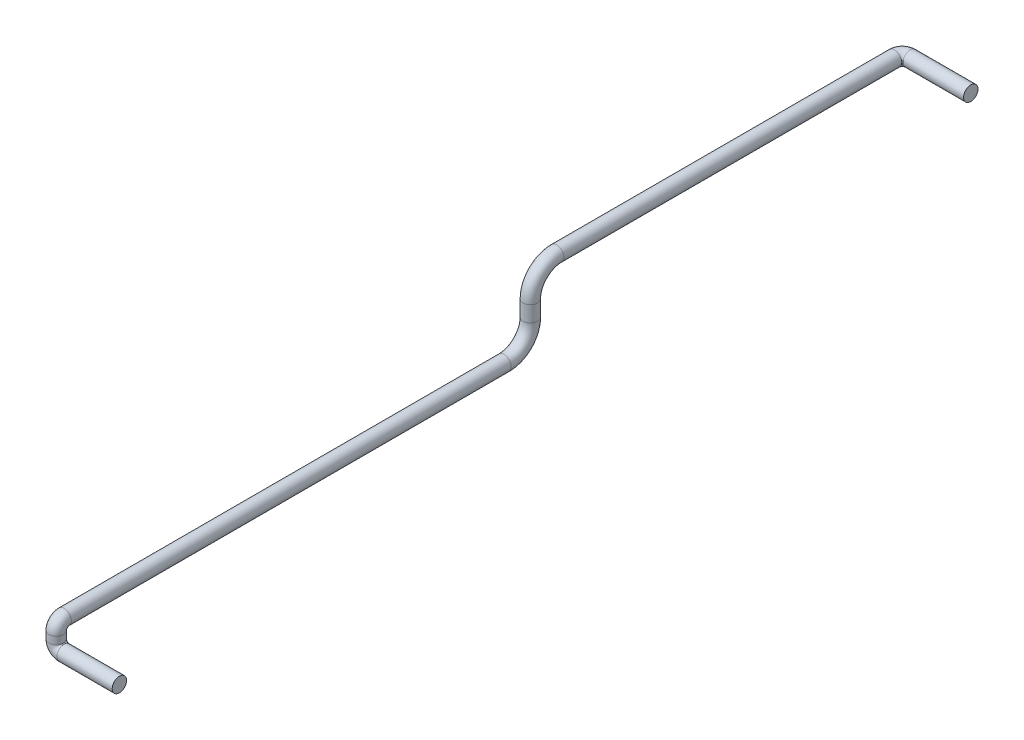
from build123d import *

# Parameters (mm, degrees)
CROQUIS1_R = 13.7


with BuildPart() as part:
    # Barrer1: sweep along a curve in space
    with BuildLine() as barrer1_path:
        Line((0, 0, 0), (-105, 0, 0))
        ThreePointArc((-105, 0, 0), (-115.606601718, 4.393398282, 0), (-120, 15, 0))
        Line((-120, 15, 0), (-120, 29, 0))
        ThreePointArc((-120, 44, -15), (-120, 39.606601718, -4.393398282), (-120, 29, 0))
        Line((-120, 44, -15), (-120, 44, -850))
        ThreePointArc((-120, 94, -900), (-120, 58.644660941, -885.355339059), (-120, 44, -850))
        Line((-120, 124, -900), (-120, 94, -900))
        ThreePointArc((-120, 124, -900), (-120, 159.355339059, -914.644660941), (-120, 174, -950))
        Line((-120, 174, -950), (-120, 174, -1591))
        ThreePointArc((-120, 174, -1591), (-115.606601718, 174, -1601.606601718), (-105, 174, -1606))
        Line((-105, 174, -1606), (10, 174, -1606))
    # Croquis1 → Barrer1 (sweep)
    with BuildSketch(Plane(origin=(0, 0, 0), x_dir=(0, 0, -1), z_dir=(1, 0, 0))):
        Circle(CROQUIS1_R)
    sweep(path=barrer1_path.line)


solid = part.part
